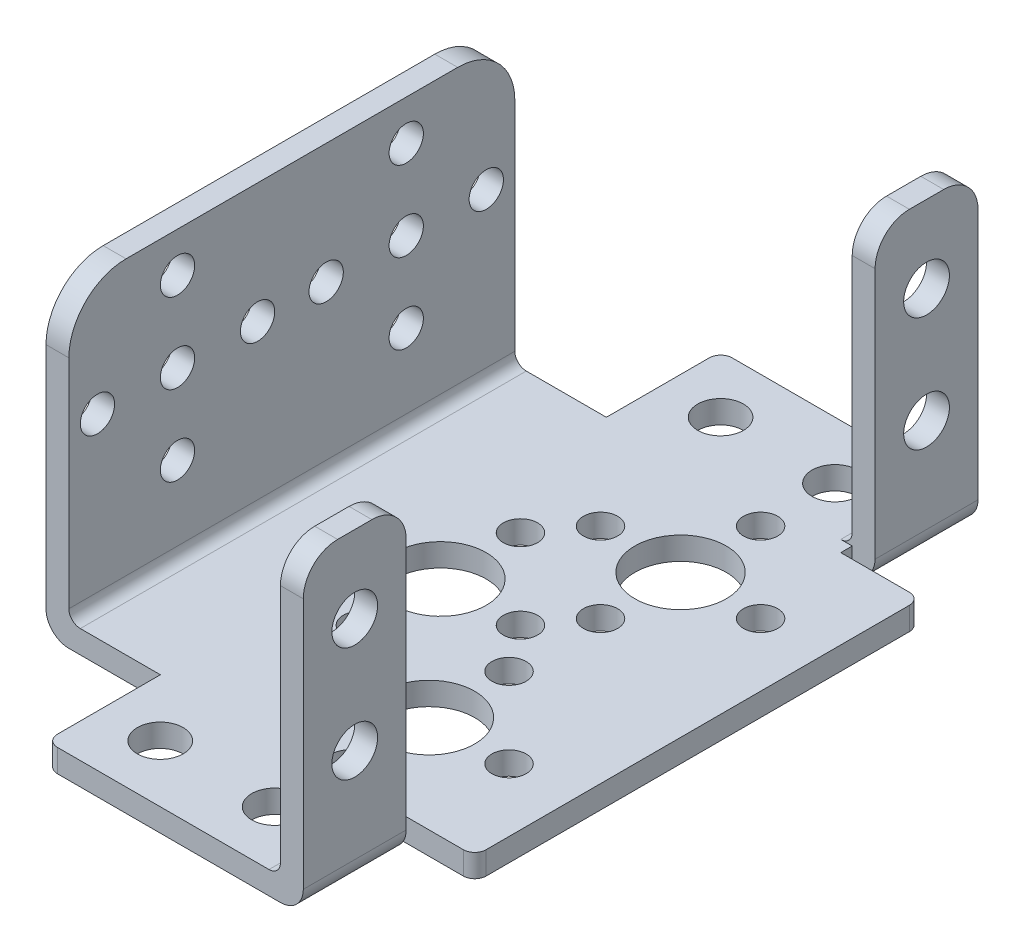
from build123d import *

# Parameters (mm, degrees)
SKETCH1_W           = 35.49
SKETCH1_H           = 39
BOSS_EXTRUDE1_DEPTH = 2
SKETCH2_W           = 20.5
SKETCH2_H           = 10
BOSS_EXTRUDE2_DEPTH = 2
SKETCH3_W           = 39
SKETCH3_H           = 27
BOSS_EXTRUDE3_DEPTH = 2
SKETCH4_W           = 9
SKETCH4_H           = 27
BOSS_EXTRUDE4_DEPTH = 2
SKETCH5_R           = 4
SKETCH5_R_2         = 2
SKETCH5_R_3         = 1.5
CUT_EXTRUDE1_DEPTH  = 2
SKETCH6_R           = 2
CUT_EXTRUDE2_DEPTH  = 2
SKETCH7_R           = 1.5
CUT_EXTRUDE3_DEPTH  = 2
FILLET1_R           = 2
FILLET2_R           = 1
FILLET3_R           = 3
FILLET4_R           = 5


with BuildPart() as part:
    # Sketch1 → Boss-Extrude1 (new body)
    with BuildSketch(Plane(origin=(0, 0, 0), x_dir=(1, 0, 0), z_dir=(0, 1, 0))):
        Rectangle(SKETCH1_W, SKETCH1_H)
    extrude(amount=BOSS_EXTRUDE1_DEPTH)

    # Sketch2 → Boss-Extrude2 (add)
    with BuildSketch(Plane(origin=(0, 2, 0), x_dir=(1, 0, 0), z_dir=(0, 1, 0))):
        with Locations((0.505, 24.5)):
            Rectangle(SKETCH2_W, SKETCH2_H)
        with Locations((0.505, -24.5)):
            Rectangle(SKETCH2_W, SKETCH2_H)
    extrude(amount=-BOSS_EXTRUDE2_DEPTH)

    # Sketch3 → Boss-Extrude3 (add)
    with BuildSketch(Plane.ZY.offset(17.745)):
        with Locations((0, 13.5)):
            Rectangle(SKETCH3_W, SKETCH3_H)
    extrude(amount=BOSS_EXTRUDE3_DEPTH)

    # Sketch4 → Boss-Extrude4 (add)
    with BuildSketch(Plane(origin=(10.755, 0, 0), x_dir=(0, 0, -1), z_dir=(1, 0, 0))):
        with Locations((-25, 13.5)):
            Rectangle(SKETCH4_W, SKETCH4_H)
        with Locations((25, 13.5)):
            Rectangle(SKETCH4_W, SKETCH4_H)
    extrude(amount=BOSS_EXTRUDE4_DEPTH)

    # Sketch5 → Cut-Extrude1 (cut)
    with BuildSketch(Plane(origin=(0, 2, 0), x_dir=(1, 0, 0), z_dir=(0, 1, 0))):
        with Locations((-4.755, 0)):
            Circle(SKETCH5_R)
        with Locations((5.245, 11)):
            Circle(SKETCH5_R)
        with Locations((5.245, -11)):
            Circle(SKETCH5_R)
        with Locations((-4.755, -24.5)):
            Circle(SKETCH5_R_2)
        with Locations((5.245, -24.5)):
            Circle(SKETCH5_R_2)
        with Locations((5.245, 24.5)):
            Circle(SKETCH5_R_2)
        with Locations((5.245, 18)):
            Circle(SKETCH5_R_3)
        with Locations((12.245, 11)):
            Circle(SKETCH5_R_3)
        with Locations((5.245, 4)):
            Circle(SKETCH5_R_3)
        with Locations((-1.755, 11)):
            Circle(SKETCH5_R_3)
        with Locations((-4.755, 7)):
            Circle(SKETCH5_R_3)
        with Locations((2.245, 0)):
            Circle(SKETCH5_R_3)
        with Locations((-4.755, -7)):
            Circle(SKETCH5_R_3)
        with Locations((-11.755, 0)):
            Circle(SKETCH5_R_3)
        with Locations((5.245, -4)):
            Circle(SKETCH5_R_3)
        with Locations((12.245, -11)):
            Circle(SKETCH5_R_3)
        with Locations((5.245, -18)):
            Circle(SKETCH5_R_3)
        with Locations((-1.755, -11)):
            Circle(SKETCH5_R_3)
        with Locations((-4.755, 24.5)):
            Circle(SKETCH5_R_2)
    extrude(amount=-CUT_EXTRUDE1_DEPTH, mode=Mode.SUBTRACT)

    # Sketch6 → Cut-Extrude2 (cut)
    with BuildSketch(Plane(origin=(12.755, 0, 0), x_dir=(0, 0, -1), z_dir=(1, 0, 0))):
        with Locations((-25, 20.25)):
            Circle(SKETCH6_R)
        with Locations((-25, 10.25)):
            Circle(SKETCH6_R)
        with Locations((25, 20.25)):
            Circle(SKETCH6_R)
        with Locations((25, 10.25)):
            Circle(SKETCH6_R)
    extrude(amount=-CUT_EXTRUDE2_DEPTH, mode=Mode.SUBTRACT)

    # Sketch7 → Cut-Extrude3 (cut)
    with BuildSketch(Plane(origin=(-17.745, 0, 0), x_dir=(0, 0, -1), z_dir=(1, 0, 0))):
        with Locations((-10, 16.5)):
            Circle(SKETCH7_R)
        with Locations((-10, 23.5)):
            Circle(SKETCH7_R)
        with Locations((-3, 16.5)):
            Circle(SKETCH7_R)
        with Locations((-10, 9.5)):
            Circle(SKETCH7_R)
        with Locations((-17, 16.5)):
            Circle(SKETCH7_R)
        with Locations((10, 16.5)):
            Circle(SKETCH7_R)
        with Locations((10, 23.5)):
            Circle(SKETCH7_R)
        with Locations((17, 16.5)):
            Circle(SKETCH7_R)
        with Locations((10, 9.5)):
            Circle(SKETCH7_R)
        with Locations((3, 16.5)):
            Circle(SKETCH7_R)
    extrude(amount=-CUT_EXTRUDE3_DEPTH, mode=Mode.SUBTRACT)

    # Fillet1
    fillet1_edges = [part.edges().sort_by_distance(p)[0] for p in [
        (-19.745, 0, 0),
        (12.755, 0, -25),
        (12.755, 0, 25),
    ]]
    fillet(fillet1_edges, radius=FILLET1_R)

    # Fillet2
    fillet2_edges = [part.edges().sort_by_distance(p)[0] for p in [
        (-17.745, 2, 0),
        (10.755, 2, -25),
        (10.755, 2, 25),
        (-9.745, 1, -29.5),
        (17.745, 1, -19.5),
        (17.745, 1, 19.5),
        (-9.745, 1, 29.5),
    ]]
    fillet(fillet2_edges, radius=FILLET2_R)

    # Fillet3
    fillet3_edges = [part.edges().sort_by_distance(p)[0] for p in [
        (11.755, 27, 29.5),
        (11.755, 27, 20.5),
        (11.755, 27, -29.5),
        (11.755, 27, -20.5),
    ]]
    fillet(fillet3_edges, radius=FILLET3_R)

    # Fillet4
    fillet4_edges = [part.edges().sort_by_distance(p)[0] for p in [
        (-18.745, 27, -19.5),
        (-18.745, 27, 19.5),
    ]]
    fillet(fillet4_edges, radius=FILLET4_R)


solid = part.part
